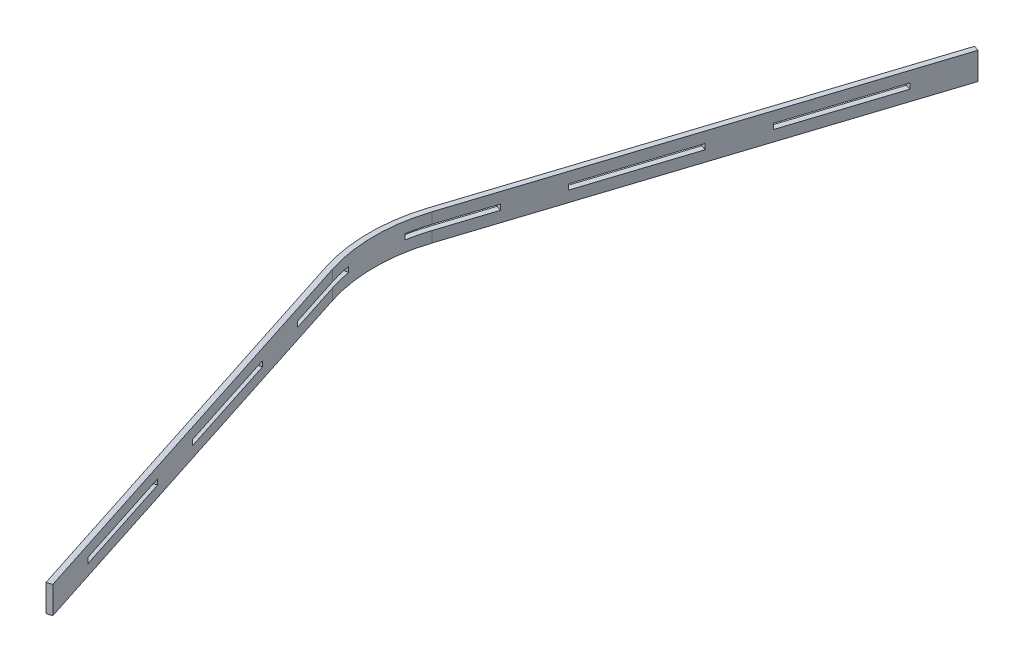
from build123d import *

# Parameters (mm, degrees)
BOSS_EXTRUDE1_DEPTH   = 5
BOSS_EXTRUDE1_2_DEPTH = 5
BOSS_EXTRUDE1_3_DEPTH = 5
BOSS_EXTRUDE1_4_DEPTH = 5
BOSS_EXTRUDE1_5_DEPTH = 5
BOSS_EXTRUDE1_6_DEPTH = 5
BOSS_EXTRUDE1_7_DEPTH = 5
BOSS_EXTRUDE2_DEPTH   = 20
BOSS_EXTRUDE3_DEPTH   = 20


with BuildPart() as part:
    # Sketch3 → Boss-Extrude1 (new body, symmetric)
    with BuildSketch(Plane(origin=(0, 0, 0), x_dir=(1, 0, 0), z_dir=(0, 1, 0))):
        Polygon((-49.523523643, -856.532206403), (-40.006093165, -853.463246139), (-70.69569581, -758.288941363), (-80.213126288, -761.357901628), align=None)
    extrude(amount=BOSS_EXTRUDE1_DEPTH, both=True)



with BuildPart() as body_2:
    # Sketch3 → Boss-Extrude1 2 (new body, symmetric)
    with BuildSketch(Plane(origin=(0, 0, 0), x_dir=(1, 0, 0), z_dir=(0, 1, 0))):
        Polygon((-132.074901101, -567.940331812), (-141.592331578, -571.009292077), (-172.281934223, -475.834987302), (-162.764503746, -472.766027037), align=None)
    extrude(amount=BOSS_EXTRUDE1_2_DEPTH, both=True)


with BuildPart() as body_3:
    # Sketch3 → Boss-Extrude1 3 (new body, symmetric)
    with BuildSketch(Plane(origin=(0, 0, 0), x_dir=(1, 0, 0), z_dir=(0, 1, 0))):
        Polygon((-233.661139514, -285.486377751), (-224.143709036, -282.417417486), (-254.833311681, -187.243112711), (-264.350742159, -190.312072975), align=None)
    extrude(amount=BOSS_EXTRUDE1_3_DEPTH, both=True)


with BuildPart() as body_4:
    # Sketch3 → Boss-Extrude1 4 (new body, symmetric)
    with BuildSketch(Plane(origin=(0, 0, 0), x_dir=(1, 0, 0), z_dir=(0, 1, 0))):
        with BuildLine():
            Line((-305.290403434, -53.830935077), (-295.442325904, -52.0944533))
            ThreePointArc((-295.442325904, -52.0944533), (-300, 0), (-295.442325904, 52.0944533))
            Line((-295.442325904, 52.0944533), (-305.290403434, 53.830935077))
            ThreePointArc((-305.290403434, 53.830935077), (-310, 0), (-305.290403434, -53.830935077))
        make_face()
    extrude(amount=BOSS_EXTRUDE1_4_DEPTH, both=True)


with BuildPart() as body_5:
    # Sketch3 → Boss-Extrude1 5 (new body, symmetric)
    with BuildSketch(Plane(origin=(0, 0, 0), x_dir=(1, 0, 0), z_dir=(0, 1, 0))):
        Polygon((-254.833311681, 187.243112711), (-224.143709036, 282.417417486), (-233.661139514, 285.486377751), (-264.350742159, 190.312072975), align=None)
    extrude(amount=BOSS_EXTRUDE1_5_DEPTH, both=True)


with BuildPart() as body_6:
    # Sketch3 → Boss-Extrude1 6 (new body, symmetric)
    with BuildSketch(Plane(origin=(0, 0, 0), x_dir=(1, 0, 0), z_dir=(0, 1, 0))):
        Polygon((-70.69569581, 758.288941363), (-40.006093165, 853.463246139), (-49.523523643, 856.532206403), (-80.213126288, 761.357901628), align=None)
    extrude(amount=BOSS_EXTRUDE1_6_DEPTH, both=True)


with BuildPart() as body_7:
    # Sketch3 → Boss-Extrude1 7 (new body, symmetric)
    with BuildSketch(Plane(origin=(0, 0, 0), x_dir=(1, 0, 0), z_dir=(0, 1, 0))):
        Polygon((-162.764503746, 472.766027037), (-132.074901101, 567.940331812), (-141.592331578, 571.009292077), (-172.281934223, 475.834987302), align=None)
    extrude(amount=BOSS_EXTRUDE1_7_DEPTH, both=True)


with BuildPart() as part_1:
    add(part.part)

    add(body_2.part)  # Boss-Extrude2 merges body 2

    add(body_3.part)  # Boss-Extrude2 merges body 3

    add(body_4.part)  # Boss-Extrude2 merges body 4

    add(body_5.part)  # Boss-Extrude2 merges body 5

    add(body_6.part)  # Boss-Extrude2 merges body 6

    add(body_7.part)  # Boss-Extrude2 merges body 7
    # Sketch4 → Boss-Extrude2 (add)
    with BuildSketch(Plane(origin=(0, 5, 0), x_dir=(1, 0, 0), z_dir=(0, 1, 0))):
        with BuildLine():
            Line((-49.523523643, 856.532206403), (-40.006093165, 853.463246139))
            Line((-40.006093165, 853.463246139), (-285.522914326, 92.068807935))
            ThreePointArc((-285.522914326, 92.068807935), (-300, 0), (-285.522914326, -92.068807935))
            Line((-285.522914326, -92.068807935), (-40.006093165, -853.463246139))
            Line((-40.006093165, -853.463246139), (-49.523523643, -856.532206403))
            Line((-49.523523643, -856.532206403), (-295.040344804, -95.1377682))
            ThreePointArc((-295.040344804, -95.1377682), (-310, 0), (-295.040344804, 95.1377682))
            Line((-295.040344804, 95.1377682), (-49.523523643, 856.532206403))
        make_face()
    extrude(amount=BOSS_EXTRUDE2_DEPTH)

    # Sketch5 → Boss-Extrude3 (add)
    with BuildSketch(Plane.XZ.offset(5)):
        with BuildLine():
            Line((-49.523523643, 856.532206403), (-40.006093165, 853.463246139))
            Line((-40.006093165, 853.463246139), (-285.522914326, 92.068807935))
            ThreePointArc((-285.522914326, 92.068807935), (-300, 0), (-285.522914326, -92.068807935))
            Line((-285.522914326, -92.068807935), (-40.006093165, -853.463246139))
            Line((-40.006093165, -853.463246139), (-49.523523643, -856.532206403))
            Line((-49.523523643, -856.532206403), (-295.040344804, -95.1377682))
            ThreePointArc((-295.040344804, -95.1377682), (-310, 0), (-295.040344804, 95.1377682))
            Line((-295.040344804, 95.1377682), (-49.523523643, 856.532206403))
        make_face()
    extrude(amount=BOSS_EXTRUDE3_DEPTH)


solid = part_1.part
